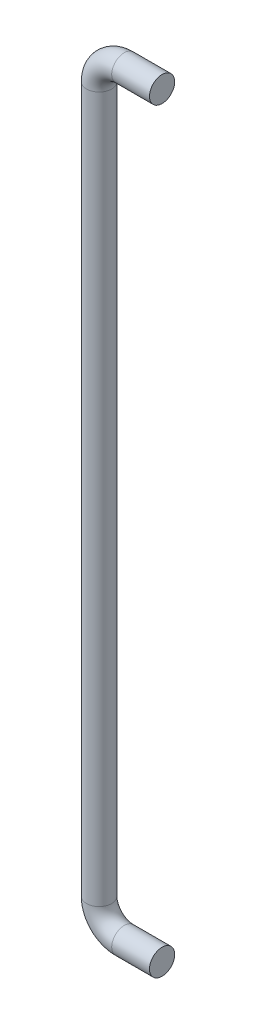
from build123d import *

# Parameters (mm, degrees)
SKIZZE2_R = 10


with BuildPart() as part:
    # Austragung1: sweep along a path in Skizze1
    with BuildLine(Plane.XY) as austragung1_path:
        Line((25, 300), (-5, 300))
        ThreePointArc((-5, 300), (-19.142135624, 294.142135624), (-25, 280))
        Line((-25, 280), (-25, -280))
        ThreePointArc((-25, -280), (-19.142135624, -294.142135624), (-5, -300))
        Line((-5, -300), (25, -300))
    # Skizze2 → Austragung1 (sweep)
    with BuildSketch(Plane(origin=(25, 0, 0), x_dir=(0, 0, -1), z_dir=(1, 0, 0))):
        with Locations((0, 300)):
            Circle(SKIZZE2_R)
    sweep(path=austragung1_path.line)


solid = part.part
